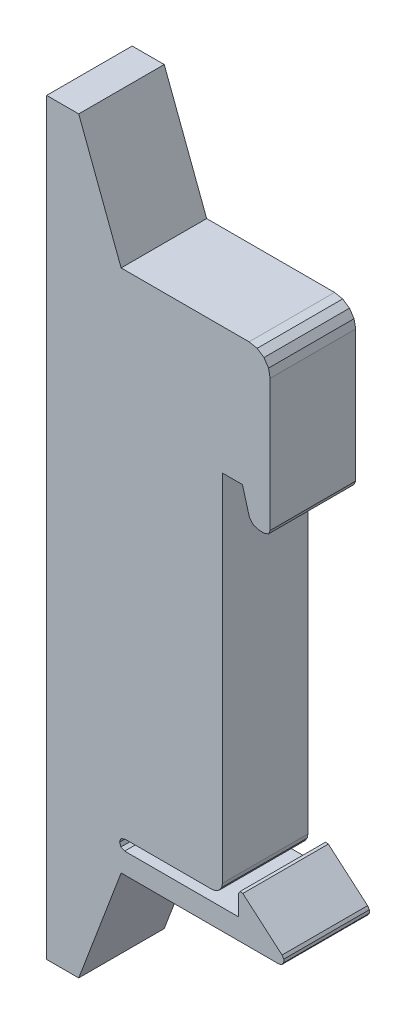
from build123d import *

# Parameters (mm, degrees)
BOSS_EXTRUDE1_DEPTH = 8
SKETCH2_W           = 8
SKETCH2_H           = 70
BOSS_EXTRUDE2_DEPTH = 3
BOSS_EXTRUDE3_DEPTH = 8
SKETCH3_R           = 1.95
CUT_EXTRUDE1_DEPTH  = 5
BOSS_EXTRUDE4_DEPTH = 8


with BuildPart() as part:
    # Model → Boss-Extrude1 (new body)
    with BuildSketch(Plane.XY):
        Polygon((17.413449519, 34.221897901), (17.762016684, 34.366278619), (17.906397402, 34.714845785), (17.906397402, 47.038542874), (17.756302008, 47.793113579), (17.328872656, 48.432811545), (16.689176573, 48.860240897), (15.934604921, 49.010334408), (0, 49.010334408), (0, 0), (18.712346706, 0), (18.997450676, 0.090807901), (19.177512865, 0.329780152), (19.186191134, 0.62886938), (19.020288696, 0.877880987), (15.349128974, 4.028884693), (15.088389968, 4.05856896), (14.948683096, 3.83642518), (14.948683096, 1.933808007), (4.297410215, 1.933808007), (3.945501494, 2.087854221), (3.823764179, 2.426754717), (3.938850818, 2.765655441), (4.297410215, 2.919701654), (12.46281762, 2.919701654), (12.846572657, 2.997178421), (13.159951014, 3.208463791), (13.371237094, 3.521841448), (13.448713387, 3.905595539), (13.448713387, 38.433111261), (14.948709154, 38.433111261), (15.975012914, 34.783087212), (16.33877785, 34.373913238), (16.864740741, 34.221897901), align=None)
    extrude(amount=BOSS_EXTRUDE1_DEPTH)

    # Sketch2 → Boss-Extrude2 (add)
    with BuildSketch(Plane.ZY):
        with Locations((4, 24.505167204)):
            Rectangle(SKETCH2_W, SKETCH2_H)
    extrude(amount=BOSS_EXTRUDE2_DEPTH)

    # Sketch4 → Boss-Extrude3 (add)
    with BuildSketch(Plane.XY.offset(8)):
        Polygon((0, 59.505167204), (3.967302461, 49.010334408), (0, 49.010334408), align=None)
        Polygon((0, 0), (0, -10.494832796), (3.967302461, 0), align=None)
    extrude(amount=-BOSS_EXTRUDE3_DEPTH)

    # Sketch3 → Cut-Extrude1 (cut)
    with BuildSketch(Plane.ZY.offset(3)):
        with Locations((4, 49.555167204)):
            Circle(SKETCH3_R)
        with Locations((4, -0.544832796)):
            Circle(SKETCH3_R)
    extrude(amount=-CUT_EXTRUDE1_DEPTH, mode=Mode.SUBTRACT)

    # Sketch5 → Boss-Extrude4 (add)
    with BuildSketch(Plane.XY.offset(8)):
        Polygon((14.948709154, 38.433111261), (15.314043683, 37.133808007), (13.448713387, 37.133808007), (13.448713387, 38.433111261), align=None)
    extrude(amount=-BOSS_EXTRUDE4_DEPTH)


solid = part.part
